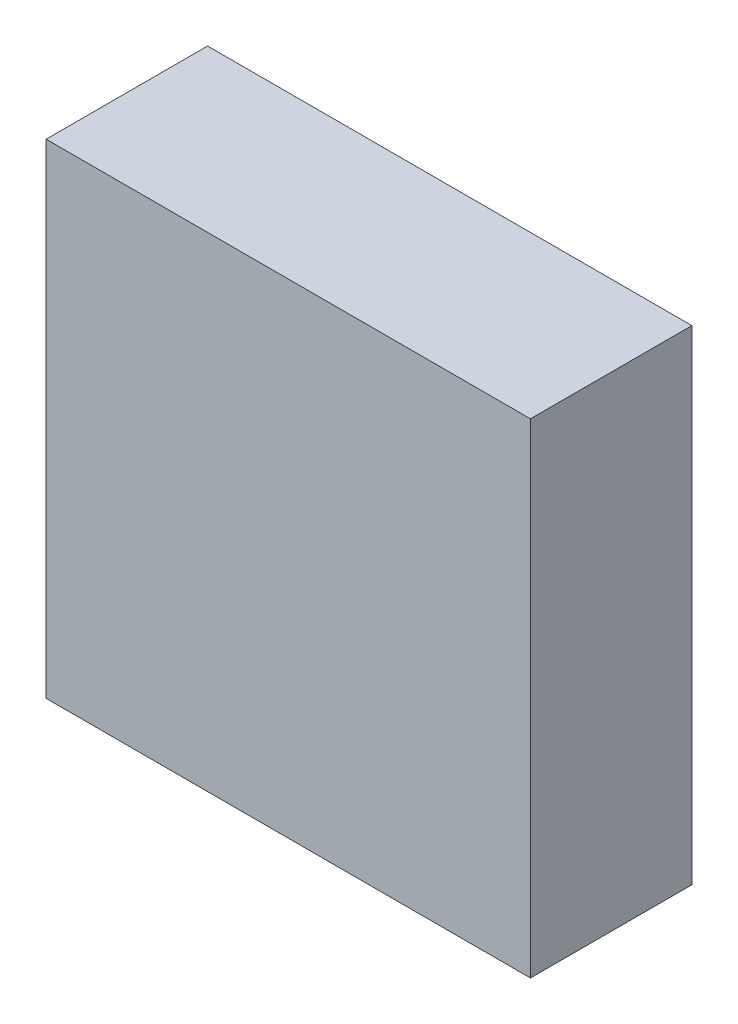
from build123d import *

# Parameters (mm, degrees)
SKETCH_1_W      = 4.8
SKETCH_1_H      = 4.8
EXTRUDE_1_DEPTH = 1.6


with BuildPart() as part:
    # Эскиз1 → Бобышка-Вытянуть1 (new body)
    with BuildSketch(Plane.XY):
        with Locations((-0.190989986, 0.203615159)):
            Rectangle(SKETCH_1_W, SKETCH_1_H)
    extrude(amount=EXTRUDE_1_DEPTH)


solid = part.part
